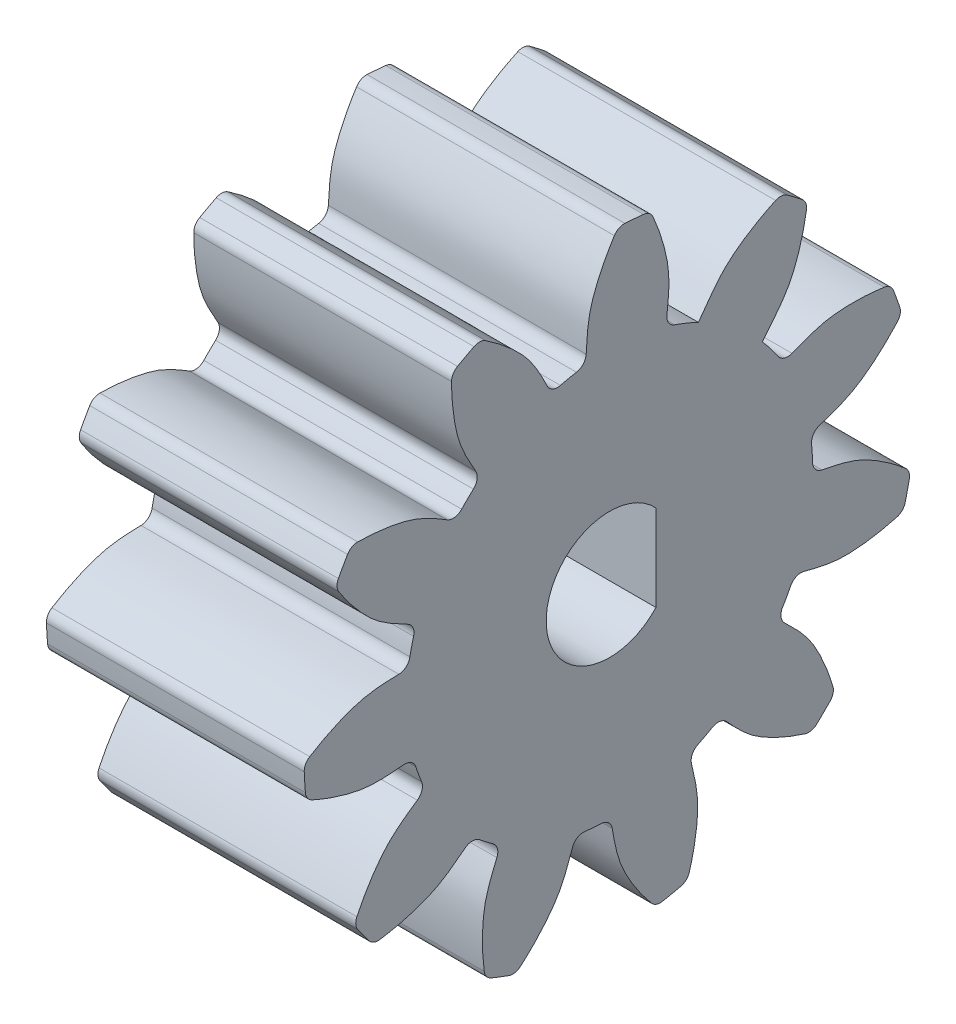
from build123d import *

# Parameters (mm, degrees)
SKETCH1_R           = 8.752484076
BOSS_EXTRUDE1_DEPTH = 11.1125
BOSS_EXTRUDE2_DEPTH = 11.1125
CIRPATTERN1_COUNT   = 11
FILLET1_R           = 0.50038
CUT_EXTRUDE1_DEPTH  = 12.1125001


with BuildPart() as part:
    # Sketch1 → Boss-Extrude1 (new body)
    with BuildSketch(Plane(origin=(0, 0, 0), x_dir=(0, 0, -1), z_dir=(1, 0, 0))):
        Circle(SKETCH1_R)
    extrude(amount=BOSS_EXTRUDE1_DEPTH)

    # Sketch2 → Boss-Extrude2 (add)
    with BuildSketch(Plane.ZY):
        with BuildLine():
            ThreePointArc((-0.369061728, 13.166468433), (-1.062388324, 13.121243495), (-1.753941018, 13.054147041))
            add(Edge.make_bspline(
                [(-2.422542308, 8.410544945), (-2.501245384, 9.099569926), (-2.634610183, 9.963745416), (-2.463718386, 10.973692162), (-2.345471756, 11.483616226), (-2.12525456, 12.19539239), (-1.909393883, 12.723906056), (-1.753941018, 13.054147041)],
                knots=[0, 0, 0, 0, 0.442213829, 0.532569284, 0.642094259, 0.770788757, 1, 1, 1, 1], degree=3))
            ThreePointArc((-2.422542308, 8.410544945), (-0.709340096, 8.723692689), (1.0319476, 8.69143611))
            add(Edge.make_bspline(
                [(1.0319476, 8.69143611), (0.985193077, 9.380322628), (0.983605872, 10.251494359), (0.657566048, 11.219346551), (0.461004361, 11.704471181), (0.131949882, 12.374045304), (-0.165485098, 12.862418299), (-0.369061728, 13.166468433)],
                knots=[0, 0, 0, 0, 0.44086973, 0.531345584, 0.641016501, 0.769882485, 1, 1, 1, 1], degree=3))
        make_face()
    boss_extrude2 = extrude(amount=-BOSS_EXTRUDE2_DEPTH)

    # CirPattern1: Boss-Extrude2 ×11 about axis
    cirpattern1_axis = Axis((0, 0, 0), (-1, 0, 0))
    for i in range(1, CIRPATTERN1_COUNT):
        add(boss_extrude2.rotate(cirpattern1_axis, i * 360 / CIRPATTERN1_COUNT))

    # Fillet1
    fillet1_edges = [part.edges().sort_by_distance(p)[0] for p in [
        (5.55625, -3.594829664, -7.980174008),
        (5.55625, -4.911786271, -7.244331104),
        (5.55625, -7.338570954, -4.769837929),
        (5.55625, -8.048638642, -3.43880699),
        (5.55625, -8.752367818, -0.045112009),
        (5.55625, -8.630105114, 1.458514046),
        (5.55625, -7.387349741, 4.693936655),
        (5.55625, -6.47157419, 5.892767178),
        (5.55625, -3.676900318, 7.942693596),
        (5.55625, -2.258364186, 8.456108367),
        (5.55625, 1.200938977, 8.669701441),
        (5.55625, 2.67186049, 8.334694897),
        (5.55625, -0.215476463, -8.749831278),
        (5.55625, 5.697488631, 6.644140336),
        (5.55625, 6.753788339, 5.567074688),
        (5.55625, 8.385125902, 2.509111619),
        (5.55625, 8.69143611, 1.0319476),
        (5.55625, 8.410544945, -2.422542308),
        (5.55625, 4.549245599, -7.477321846),
        (5.55625, 1.290244644, -8.656861225),
        (5.55625, 7.018329531, 11.145856389),
        (5.55625, 5.805259012, 11.82332717),
        (5.55625, -0.121710397, 13.170886479),
        (5.55625, -1.508478614, 13.084975729),
        (5.55625, -7.223108134, 11.014253172),
        (5.55625, -8.343284938, 10.192236948),
        (5.55625, -12.031220074, 5.360672307),
        (5.55625, -12.529157245, 4.063534951),
        (5.55625, -13.01950465, -1.99488414),
        (5.55625, -12.737110653, -3.355310681),
        (5.55625, -9.87418849, -8.717078967),
        (5.55625, -8.901121426, -9.70886888),
        (5.55625, -3.593887253, -12.671662814),
        (5.55625, -2.239089038, -12.979929809),
        (5.55625, 3.827447794, -12.603083251),
        (5.55625, 5.133838299, -12.129954735),
        (5.55625, 10.03359521, -8.533113806),
        (5.55625, 10.87680825, -7.428804739),
        (5.55625, 11.275867919, 6.807855774),
        (5.55625, 11.930099422, 5.582095649),
        (5.55625, 13.166468433, -0.369061728),
        (5.55625, 13.054147041, -1.753941018),
    ]]
    fillet(fillet1_edges, radius=FILLET1_R)

    # Sketch3 → Cut-Extrude1 (cut, through all)
    with BuildSketch(Plane.ZY):
        with BuildLine():
            ThreePointArc((-2, 1.858932557), (2.7305, 0), (-2, -1.858932557))
            Line((-2, -1.858932557), (-2, 1.858932557))
        make_face()
    extrude(amount=-CUT_EXTRUDE1_DEPTH, mode=Mode.SUBTRACT)


solid = part.part
